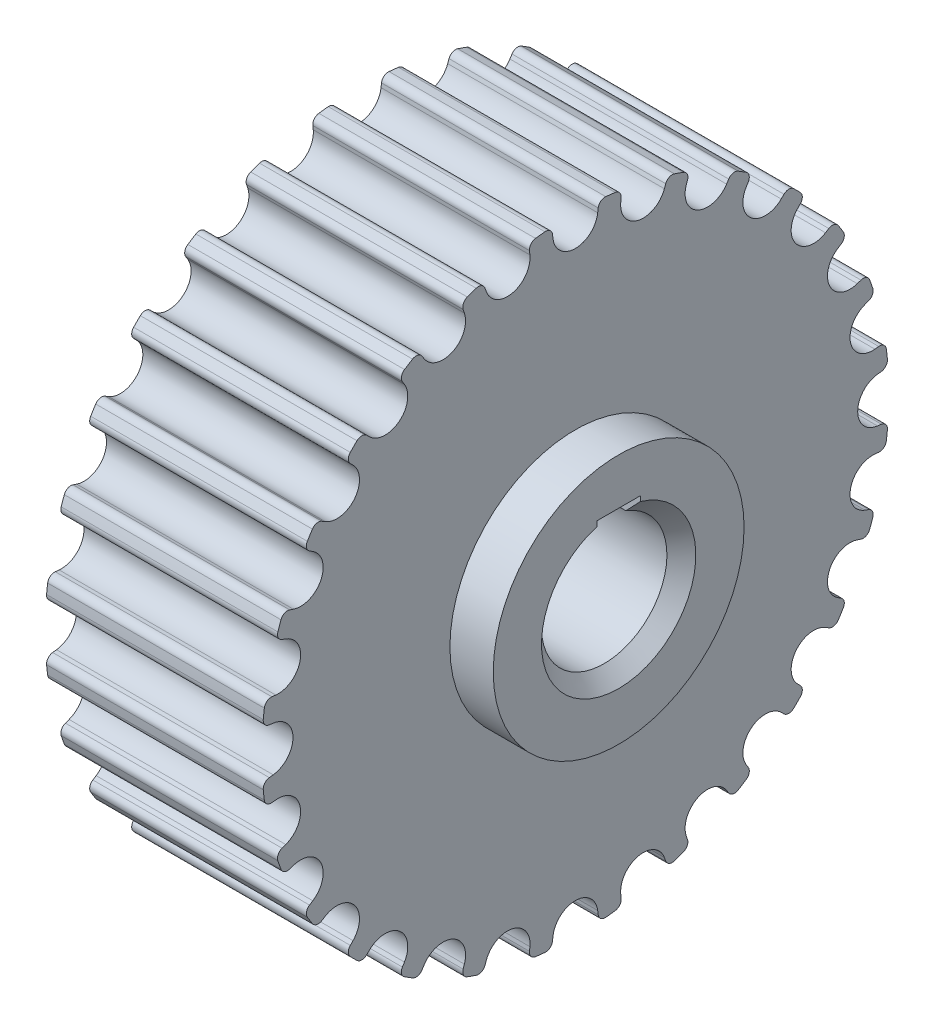
from build123d import *

# Parameters (mm, degrees)
CHAMFER_1_SIZE           = 1
SKETCH_4_W               = 3
SKETCH_4_H               = 1.399999977
CUT_EXTRUDE_1_DEPTH      = 36.587561422
CUT_EXTRUDE_2_REACH      = 37.588
PATTERN_CIRCULAR_3_COUNT = 28


with BuildPart() as part:
    # 草图1 → 旋转1 (revolve)
    with BuildSketch(Plane.XY):
        Polygon((0, 4.3416), (0, 21.708), (15, 21.708), (15, 8.6832), (18, 8.6832), (18, 4.3416), align=None)
    revolve(axis=Axis((0, 0, 0), (1, 0, 0)))

    # 倒角1
    chamfer_1_edges = [part.edges().sort_by_distance(p)[0] for p in [
        (18, -4.3416, 0),
        (0, -4.3416, 0),
    ]]
    chamfer(chamfer_1_edges, length=CHAMFER_1_SIZE)

    # 草图4 → 切除-拉伸1 (cut, through all)
    with BuildSketch(Plane.ZY):
        with Locations((0, 4.774247226)):
            Rectangle(SKETCH_4_W, SKETCH_4_H)
    extrude(amount=-CUT_EXTRUDE_1_DEPTH, mode=Mode.SUBTRACT)

    # 草图6 → 切除-拉伸2 (cut, up to next)
    with BuildSketch(Plane(origin=(0, 0, 0), x_dir=(0, 0, -1), z_dir=(1, 0, 0)), mode=Mode.PRIVATE) as cut_extrude_2_sk1:
        with BuildLine():
            Line((1.58135691, 21.186524389), (1.548371997, 20.917883824))
            ThreePointArc((1.548371997, 20.917883824), (0, 19.548), (-1.548371997, 20.917883824))
            Line((-1.548371997, 20.917883824), (-1.58135691, 21.186524389))
            ThreePointArc((-1.58135691, 21.186524389), (-1.757541052, 21.502536299), (-2.104308833, 21.605766553))
            ThreePointArc((-2.104308833, 21.605766553), (-2.343049947, 21.581181176), (-2.581504658, 21.55395782))
            Line((-2.581504658, 21.55395782), (-2.778152646, 23.155527162))
            ThreePointArc((-2.778152646, 23.155527162), (0, 23.321590218), (2.778152646, 23.155527162))
            Line((2.778152646, 23.155527162), (2.581504658, 21.55395782))
            ThreePointArc((2.581504658, 21.55395782), (2.343049947, 21.581181176), (2.104308833, 21.605766553))
            ThreePointArc((2.104308833, 21.605766553), (1.757541052, 21.502536299), (1.58135691, 21.186524389))
        make_face()
    cut_extrude_2_tool1 = extrude(cut_extrude_2_sk1.sketch, amount=CUT_EXTRUDE_2_REACH, mode=Mode.PRIVATE) & part.part
    cut_extrude_2 = cut_extrude_2_tool1.solids().sort_by_distance((0, 21.791195, 0))[0]
    add(cut_extrude_2, mode=Mode.SUBTRACT)

    # 阵列(圆周)3: 切除-拉伸2 ×28 about axis
    pattern_circular_3_axis = Axis((-1.4, 0, 0), (1, 0, 0))
    for i in range(1, PATTERN_CIRCULAR_3_COUNT):
        add(cut_extrude_2.rotate(pattern_circular_3_axis, i * 360 / PATTERN_CIRCULAR_3_COUNT), mode=Mode.SUBTRACT)


solid = part.part
